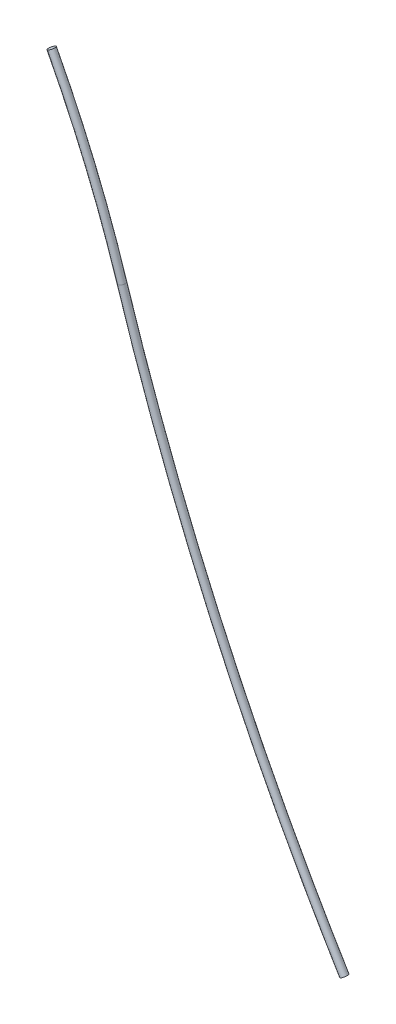
from build123d import *

# Parameters (mm, degrees)
VARREDURA1_PROFILE_R = 1


with BuildPart() as part:
    # Varredura1: sweep along a path in Esboço1
    with BuildLine(Plane.XY) as varredura1_path:
        ThreePointArc((-59.120554028, 114.27393769), (-48.10479989, 90.834212195), (-39.160570584, 66.52848586))
        ThreePointArc((-39.160570584, 66.52848586), (-11.698221448, -4.679544498), (23.934193748, -72.170989844))
    # Varredura1 profile (on start of the path) → Varredura1 (sweep)
    with BuildSketch(Plane(origin=(-59.120554028, 114.27393769, 0), x_dir=(-0.885750222, -0.464162196, 0), z_dir=(0.464162196, -0.885750222, 0))):
        Circle(VARREDURA1_PROFILE_R)
    sweep(path=varredura1_path.line)


solid = part.part
